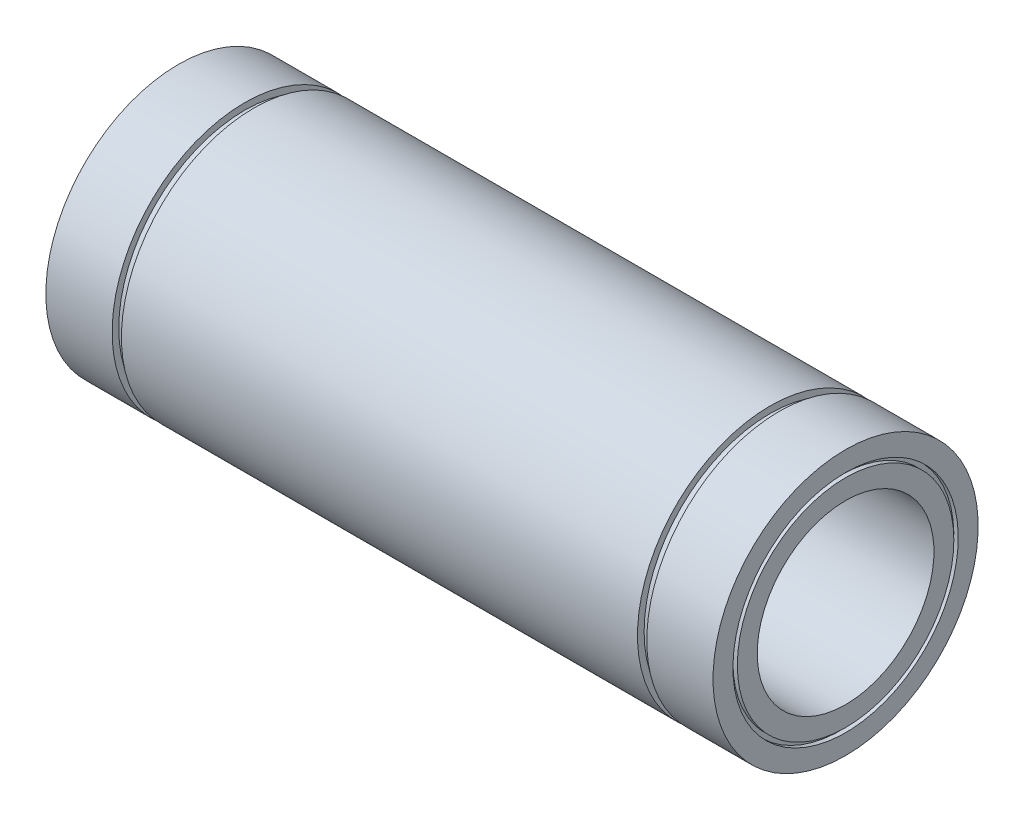
from build123d import *


with BuildPart() as part:
    # Esboço1 → Revolução1 (revolve)
    with BuildSketch(Plane.XY):
        Polygon((-75.5, 30), (-60.5, 30), (-60.5, 28.5), (-58.4, 28.5), (-58.4, 30), (58.4, 30), (58.4, 28.5), (60.5, 28.5), (60.5, 30), (75.5, 30), (75.5, 25.5), (74.5, 25.5), (74.5, 24.5), (75.5, 24.5), (75.5, 20), (-75.5, 20), (-75.5, 24.5), (-74.5, 24.5), (-74.5, 25.5), (-75.5, 25.5), align=None)
    revolve(axis=Axis((0, 0, 0), (-1, 0, 0)))


solid = part.part
